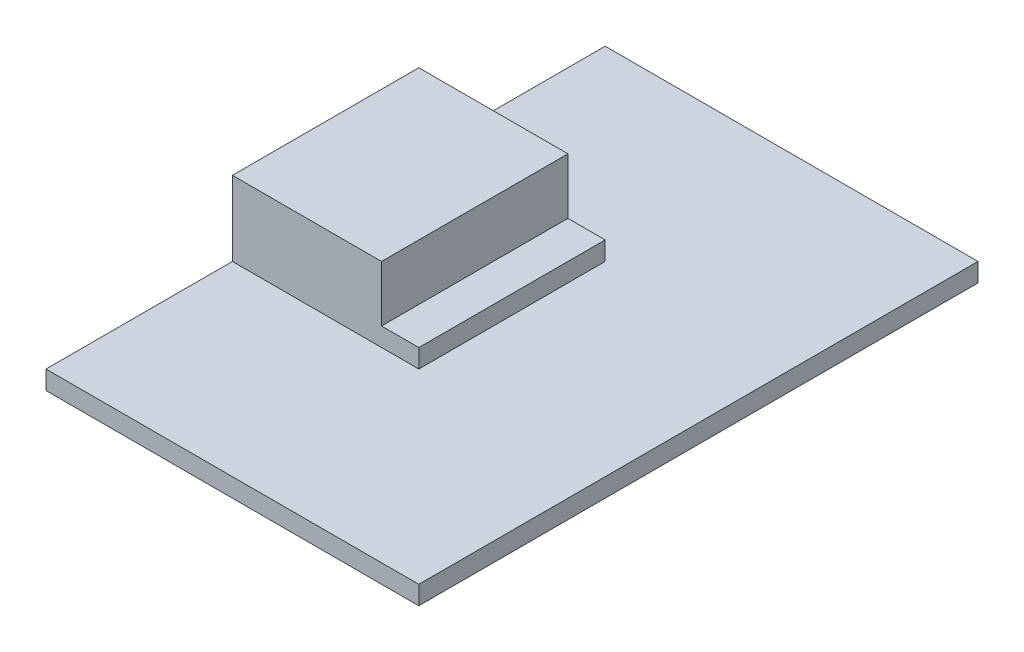
from build123d import *

# Parameters (mm, degrees)
SCHIZZO1_W                   = 8
SCHIZZO1_H                   = 10
ESTRUSIONE_ESTRUSIONE1_DEPTH = 5
SCHIZZO2_W                   = 10
SCHIZZO2_H                   = 2
ESTRUSIONE_ESTRUSIONE2_DEPTH = 2
SCHIZZO3_W                   = 20
SCHIZZO3_H                   = 30
ESTRUSIONE_ESTRUSIONE3_DEPTH = 1


with BuildPart() as part:
    # Schizzo1 → Estrusione-Estrusione1 (new body)
    with BuildSketch(Plane(origin=(0, 0, 0), x_dir=(1, 0, 0), z_dir=(0, 1, 0))):
        Rectangle(SCHIZZO1_W, SCHIZZO1_H)
    extrude(amount=ESTRUSIONE_ESTRUSIONE1_DEPTH)

    # Schizzo2 → Estrusione-Estrusione2 (add)
    with BuildSketch(Plane(origin=(4, 0, 0), x_dir=(0, 0, -1), z_dir=(1, 0, 0))):
        with Locations((0, 1)):
            Rectangle(SCHIZZO2_W, SCHIZZO2_H)
    extrude(amount=ESTRUSIONE_ESTRUSIONE2_DEPTH)

    # Schizzo3 → Estrusione-Estrusione3 (add)
    with BuildSketch(Plane.XZ):
        with Locations((6, 0)):
            Rectangle(SCHIZZO3_W, SCHIZZO3_H)
    extrude(amount=-ESTRUSIONE_ESTRUSIONE3_DEPTH)


solid = part.part
